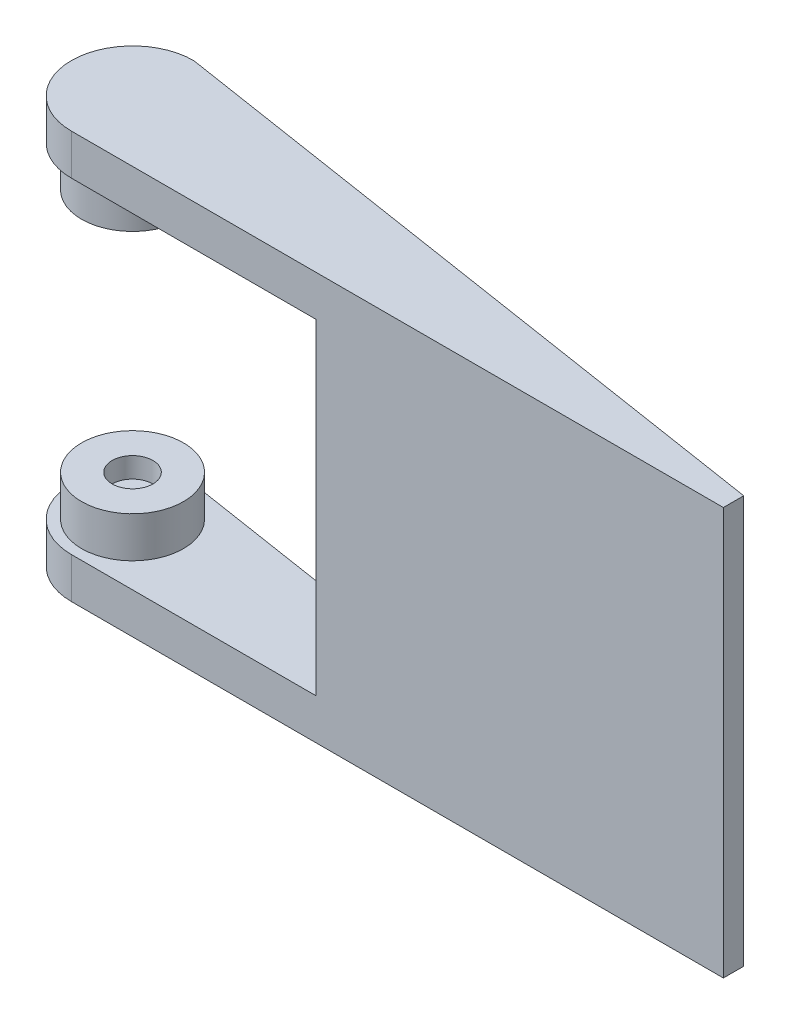
from build123d import *

# Parameters (mm, degrees)
BOSS_EXTRUDE1_DEPTH = 50
SKETCH2_R           = 12.5
CUT_EXTRUDE1_DEPTH  = 40
SKETCH3_R           = 12.5
CUT_EXTRUDE2_DEPTH  = 30
SKETCH4_R           = 5
CUT_EXTRUDE3_DEPTH  = 5


with BuildPart() as part:
    # Sketch1 → Boss-Extrude1 (new body)
    with BuildSketch(Plane(origin=(0, 0, 0), x_dir=(1, 0, 0), z_dir=(0, 1, 0))):
        with BuildLine():
            Line((0, -15), (0, 15))
            ThreePointArc((0, 15), (-15, 0), (0, -15))
        make_face()
        with BuildLine():
            Line((4.575786463, 14.285033365), (0, 15))
            Line((0, 15), (0, -15))
            ThreePointArc((0, -15), (10.606601718, -10.606601718), (15, 0))
            ThreePointArc((15, 0), (12.116864218, 8.842036051), (4.575786463, 14.285033365))
        make_face()
        with BuildLine():
            Line((160, -10), (4.575786463, 14.285033365))
            ThreePointArc((4.575786463, 14.285033365), (12.116864218, 8.842036051), (15, 0))
            ThreePointArc((15, 0), (10.606601718, -10.606601718), (0, -15))
            Line((0, -15), (160, -15))
            Line((160, -15), (160, -10))
        make_face()
    boss_extrude1 = extrude(amount=BOSS_EXTRUDE1_DEPTH)

    # Sketch2 → Cut-Extrude1 (cut)
    with BuildSketch(Plane(origin=(0, 50, 0), x_dir=(1, 0, 0), z_dir=(0, 1, 0))):
        with BuildLine():
            ThreePointArc((15, 0), (10.606601718, -10.606601718), (0, -15))
            Line((0, -15), (60, -15))
            Line((60, -15), (60, 5.625))
            Line((60, 5.625), (4.575786463, 14.285033365))
            ThreePointArc((4.575786463, 14.285033365), (12.116864218, 8.842036051), (15, 0))
        make_face()
        with BuildLine():
            ThreePointArc((0, 15), (-15, 0), (0, -15))
            ThreePointArc((0, -15), (10.606601718, -10.606601718), (15, 0))
            ThreePointArc((15, 0), (12.116864218, 8.842036051), (4.575786463, 14.285033365))
            Line((4.575786463, 14.285033365), (0, 15))
        make_face()
        Circle(SKETCH2_R, mode=Mode.SUBTRACT)
    cut_extrude1 = extrude(amount=-CUT_EXTRUDE1_DEPTH, mode=Mode.SUBTRACT)

    # Sketch3 → Cut-Extrude2 (cut)
    with BuildSketch(Plane(origin=(0, 50, 0), x_dir=(1, 0, 0), z_dir=(0, 1, 0))):
        Circle(SKETCH3_R)
    cut_extrude2 = extrude(amount=-CUT_EXTRUDE2_DEPTH, mode=Mode.SUBTRACT)

    # Sketch4 → Cut-Extrude3 (cut)
    with BuildSketch(Plane(origin=(0, 20, 0), x_dir=(1, 0, 0), z_dir=(0, 1, 0))):
        Circle(SKETCH4_R)
    cut_extrude3 = extrude(amount=-CUT_EXTRUDE3_DEPTH, mode=Mode.SUBTRACT)

    # Mirror1: Boss-Extrude1, Cut-Extrude1, Cut-Extrude2, Cut-Extrude3 across plane
    add(boss_extrude1.mirror(Plane.ZX.offset(50)))
    add(cut_extrude1.mirror(Plane.ZX.offset(50)), mode=Mode.SUBTRACT)
    add(cut_extrude2.mirror(Plane.ZX.offset(50)), mode=Mode.SUBTRACT)
    add(cut_extrude3.mirror(Plane.ZX.offset(50)), mode=Mode.SUBTRACT)


solid = part.part
